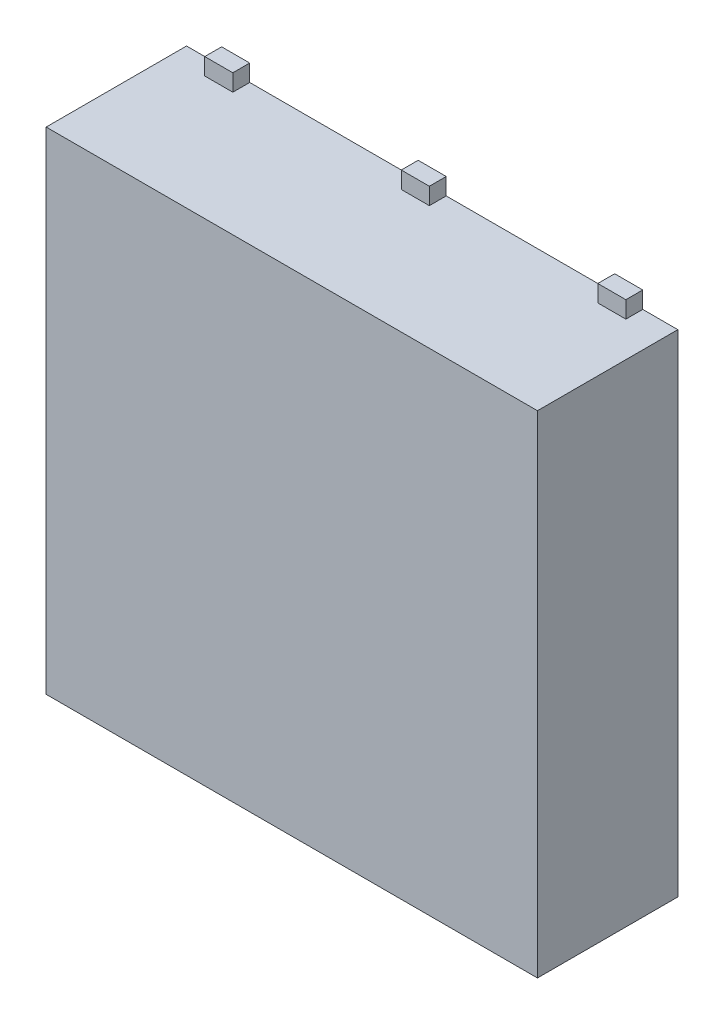
from build123d import *

# Parameters (mm, degrees)
ESQUISSE1_W                = 3.5
ESQUISSE1_H                = 3.5
BOSS_EXTRU_1_DEPTH         = 1
ESQUISSE2_W                = 0.2
ESQUISSE2_H                = 0.120247062
BOSS_EXTRU_2_DEPTH         = 0.12
R_P_TITION_LIN_AIRE1_COUNT = 2
R_P_TITION_LIN_AIRE1_PITCH = 1.4
R_P_TITION_LIN_AIRE2_COUNT = 2
R_P_TITION_LIN_AIRE2_PITCH = 1.4
SYM_TRIE1_COPY_1_SKETCH_W  = 0.2
SYM_TRIE1_COPY_1_SKETCH_H  = 0.120247062
SYM_TRIE1_COPY_1_DEPTH     = 0.12
SYM_TRIE1_COPY_2_SKETCH_W  = 0.2
SYM_TRIE1_COPY_2_SKETCH_H  = 0.120247062
SYM_TRIE1_COPY_2_DEPTH     = 0.12


with BuildPart() as part:
    # Esquisse1 → Boss.-Extru.1 (new body)
    with BuildSketch(Plane.XY):
        Rectangle(ESQUISSE1_W, ESQUISSE1_H)
    extrude(amount=BOSS_EXTRU_1_DEPTH)

    # Esquisse2 → Boss.-Extru.2 (add)
    with BuildSketch(Plane(origin=(0, 1.75, 0), x_dir=(1, 0, 0), z_dir=(0, 1, 0))):
        with Locations((0, -0.060123531)):
            Rectangle(ESQUISSE2_W, ESQUISSE2_H)
    boss_extru_2 = extrude(amount=BOSS_EXTRU_2_DEPTH)

    # Répétition linéaire1: Boss.-Extru.2 ×2
    with Locations(*[(-i * R_P_TITION_LIN_AIRE1_PITCH, 0, 0) for i in range(1, R_P_TITION_LIN_AIRE1_COUNT)]):
        add(boss_extru_2)

    # Répétition linéaire2: Boss.-Extru.2 ×2
    with Locations(*[(i * R_P_TITION_LIN_AIRE2_PITCH, 0, 0) for i in range(1, R_P_TITION_LIN_AIRE2_COUNT)]):
        add(boss_extru_2)

    # Symétrie1: Boss.-Extru.2 across plane
    add(boss_extru_2.mirror(Plane.ZX))

    # Symétrie1 copy 1 sketch → Symétrie1 copy 1 (add)
    with BuildSketch(Plane(origin=(1.4, -1.75, 0), x_dir=(1, 0, 0), z_dir=(0, -1, 0))):
        with Locations((0, 0.060123531)):
            Rectangle(SYM_TRIE1_COPY_1_SKETCH_W, SYM_TRIE1_COPY_1_SKETCH_H)
    extrude(amount=SYM_TRIE1_COPY_1_DEPTH)

    # Symétrie1 copy 2 sketch → Symétrie1 copy 2 (add)
    with BuildSketch(Plane(origin=(-1.4, -1.75, 0), x_dir=(1, 0, 0), z_dir=(0, -1, 0))):
        with Locations((0, 0.060123531)):
            Rectangle(SYM_TRIE1_COPY_2_SKETCH_W, SYM_TRIE1_COPY_2_SKETCH_H)
    extrude(amount=SYM_TRIE1_COPY_2_DEPTH)


solid = part.part
